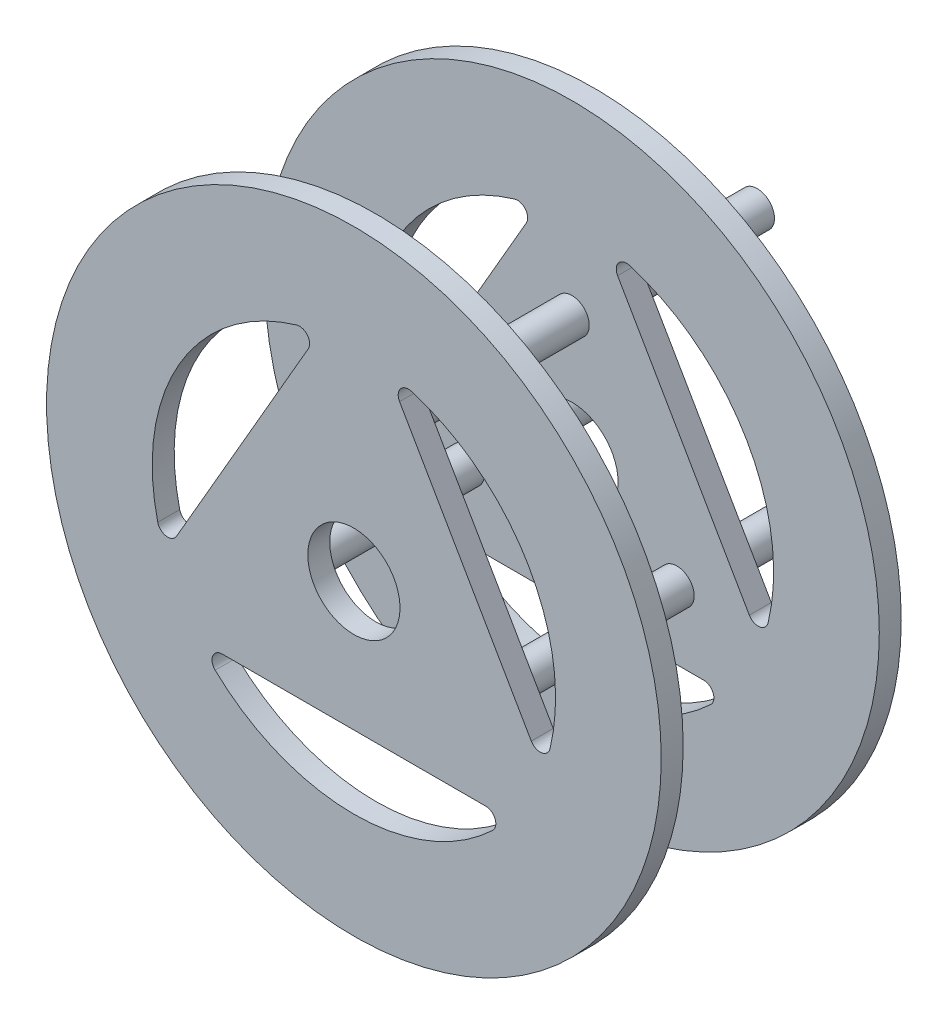
from build123d import *

# Parameters (mm, degrees)
SKETCH1_R           = 26.67
BOSS_EXTRUDE1_DEPTH = 20.828
SKETCH4_R           = 1.5
SKETCH4_R_2         = 4
CUT_EXTRUDE2_DEPTH  = 21.828
CUT_EXTRUDE3_START  = -10.414
SKETCH5_R           = 26.67
CUT_EXTRUDE3_DEPTH  = 8.509
BOSS_EXTRUDE2_START = 10.414
SKETCH9_R           = 1.5
BOSS_EXTRUDE2_DEPTH = 35


with BuildPart() as part:
    # Sketch1 → Boss-Extrude1 (new body)
    with BuildSketch(Plane.XY):
        Circle(SKETCH1_R)
    extrude(amount=BOSS_EXTRUDE1_DEPTH)

    # Sketch4 → Cut-Extrude2 (cut, through all)
    with BuildSketch(Plane(origin=(0, 0, 0), x_dir=(-1, 0, 0), z_dir=(0, 0, -1))):
        with Locations((0, 10.517)):
            Circle(SKETCH4_R)
        with Locations((9.107989172, -5.2585)):
            Circle(SKETCH4_R)
        with Locations((-9.107989172, -5.2585)):
            Circle(SKETCH4_R)
        Circle(SKETCH4_R_2)
        with BuildLine():
            Line((-3.962833887, 15.486170365), (-15.392833887, -4.311170365))
            ThreePointArc((-15.392833887, -4.311170365), (-16.285992128, -4.744214498), (-17.018969403, -4.074884104))
            ThreePointArc((-17.018969403, -4.074884104), (-15.155444566, 8.75), (-4.98053155, 16.776301901))
            ThreePointArc((-4.98053155, 16.776301901), (-4.034385787, 16.476190157), (-3.962833887, 15.486170365))
        make_face()
        with BuildLine():
            Line((15.392833887, -4.311170365), (3.962833887, 15.486170365))
            ThreePointArc((3.962833887, 15.486170365), (4.034385787, 16.476190157), (4.98053155, 16.776301901))
            ThreePointArc((4.98053155, 16.776301901), (15.155444566, 8.75), (17.018969403, -4.074884104))
            ThreePointArc((17.018969403, -4.074884104), (16.285992128, -4.744214498), (15.392833887, -4.311170365))
        make_face()
        with BuildLine():
            Line((-11.43, -11.175), (11.43, -11.175))
            ThreePointArc((11.43, -11.175), (12.25160634, -11.731975659), (12.038437853, -12.701417798))
            ThreePointArc((12.038437853, -12.701417798), (0, -17.5), (-12.038437853, -12.701417798))
            ThreePointArc((-12.038437853, -12.701417798), (-12.25160634, -11.731975659), (-11.43, -11.175))
        make_face()
    extrude(amount=-CUT_EXTRUDE2_DEPTH, mode=Mode.SUBTRACT)

    # Sketch5 → Cut-Extrude3 (cut, symmetric)
    with BuildSketch(Plane(origin=(0, 0, 0), x_dir=(-1, 0, 0), z_dir=(0, 0, -1)).offset(CUT_EXTRUDE3_START)):
        Circle(SKETCH5_R)
    extrude(amount=CUT_EXTRUDE3_DEPTH, both=True, mode=Mode.SUBTRACT)

    # Sketch9 → Boss-Extrude2 (add)
    with BuildSketch(Plane.XY.offset(10.414).offset(BOSS_EXTRUDE2_START)):
        with Locations((0, 10.517)):
            Circle(SKETCH9_R)
        with Locations((9.107989172, -5.2585)):
            Circle(SKETCH9_R)
        with Locations((-9.107989172, -5.2585)):
            Circle(SKETCH9_R)
    extrude(amount=-BOSS_EXTRUDE2_DEPTH)


solid = part.part
